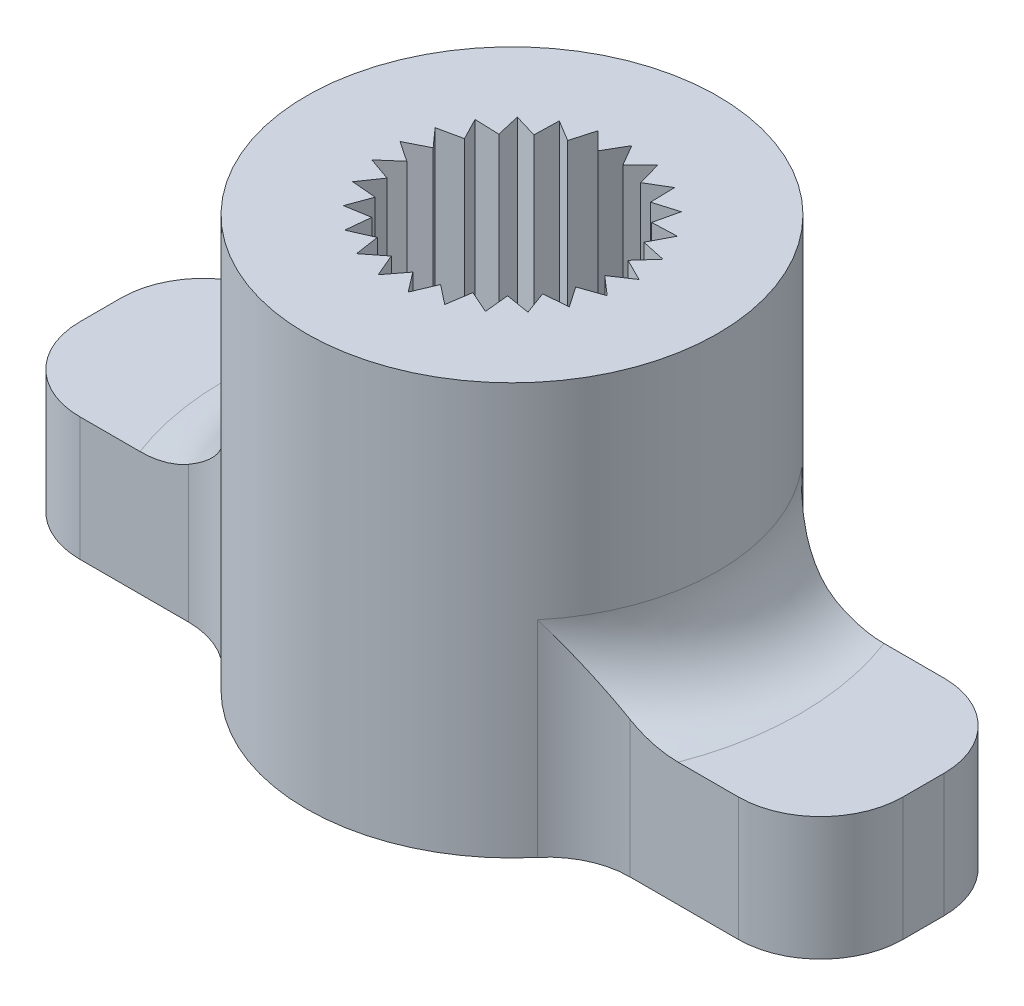
from build123d import *

# Parameters (mm, degrees)
SKETCH3_R           = 5
BOSS_EXTRUDE1_DEPTH = 10
SKETCH4_W           = 20
SKETCH4_H           = 5
BOSS_EXTRUDE2_DEPTH = 3
CUT_EXTRUDE1_DEPTH  = 11
FILLET2_R           = 2


with BuildPart() as part:
    # Sketch3 → Boss-Extrude1 (new body)
    with BuildSketch(Plane(origin=(0, 0, 0), x_dir=(1, 0, 0), z_dir=(0, 1, 0))):
        Circle(SKETCH3_R)
    extrude(amount=BOSS_EXTRUDE1_DEPTH)

    # Sketch4 → Boss-Extrude2 (add)
    with BuildSketch(Plane.XZ):
        Rectangle(SKETCH4_W, SKETCH4_H)
    extrude(amount=-BOSS_EXTRUDE2_DEPTH)

    # Sketch2 → Cut-Extrude1 (cut, through all)
    with BuildSketch(Plane(origin=(0, 0, 0), x_dir=(1, 0, 0), z_dir=(0, 1, 0))):
        Polygon((-0.302053093, 2.39099643), (0, 2.91), (0.302053093, 2.39099643), (0.723687572, 2.818576999), (0.887180172, 2.240761331), (1.401903192, 2.550052439), (1.416562458, 1.949730956), (1.992032078, 2.121298706), (1.856936915, 1.536191815), (2.456994263, 1.559255973), (2.180633196, 1.026128093), (2.767574462, 0.899239454), (2.367312274, 0.451588968), (2.90425778, 0.182720412), (2.405244416, -0.151325152), (2.8584559, -0.545279625), (2.292046204, -0.744730956), (2.633046723, -1.239017738), (2.0348303, -1.291342576), (2.242193536, -1.85490381), (1.649758525, -1.756814392), (1.710455084, -2.354239454), (1.161026355, -2.111899099), (1.071242448, -2.705649574), (0.599342628, -2.334285418), (0.36471971, -2.887053781), (0, -2.41), (-0.36471971, -2.887053781), (-0.599342628, -2.334285418), (-1.071242448, -2.705649574), (-1.161026355, -2.111899099), (-1.710455084, -2.354239454), (-1.649758525, -1.756814392), (-2.242193536, -1.85490381), (-2.0348303, -1.291342576), (-2.633046723, -1.239017738), (-2.292046204, -0.744730956), (-2.8584559, -0.545279625), (-2.405244416, -0.151325152), (-2.90425778, 0.182720412), (-2.367312274, 0.451588968), (-2.767574462, 0.899239454), (-2.180633196, 1.026128093), (-2.456994263, 1.559255973), (-1.856936915, 1.536191815), (-1.992032078, 2.121298706), (-1.416562458, 1.949730956), (-1.401903192, 2.550052439), (-0.887180172, 2.240761331), (-0.723687572, 2.818576999), align=None)
    extrude(amount=CUT_EXTRUDE1_DEPTH, mode=Mode.SUBTRACT)

    # Fillet2
    fillet2_edges = [part.edges().sort_by_distance(p)[0] for p in [
        (10, 1.5, -2.5),
        (-10, 1.5, 2.5),
        (10, 1.5, 2.5),
        (4.330127019, 1.5, -2.5),
        (-4.330127019, 1.5, -2.5),
        (-10, 1.5, -2.5),
        (-4.330127019, 1.5, 2.5),
        (4.330127019, 1.5, 2.5),
        (-5, 3, 0),
        (4.829629131, 3, -1.294095226),
    ]]
    fillet(fillet2_edges, radius=FILLET2_R)


solid = part.part
